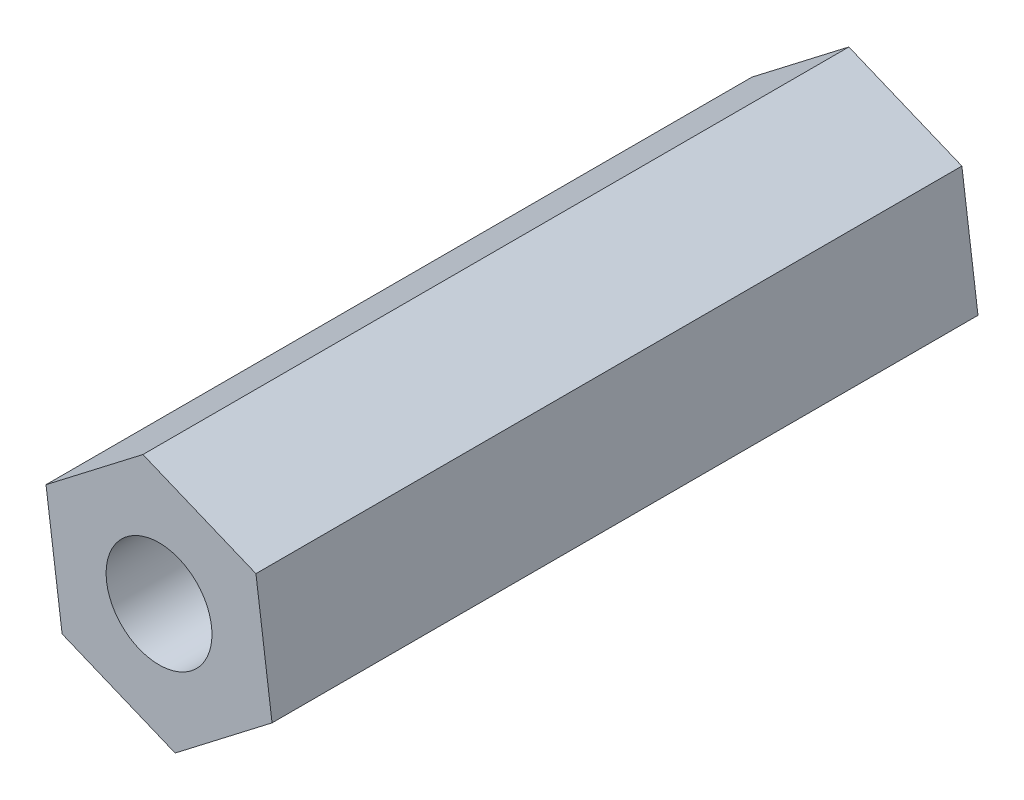
from build123d import *

# Parameters (mm, degrees)
RESSALTO_EXTRUS_O1_DEPTH = 20
ESBO_O2_R                = 1.5
CORTE_EXTRUS_O1_DEPTH    = 20


with BuildPart() as part:
    # Esboço1 → Ressalto-extrusão1 (new body)
    with BuildSketch(Plane.XY):
        Polygon((8.733866008, -0.990987001), (5.531707571, 0.330444551), (2.786235059, -1.781990226), (3.242920984, -5.215856555), (6.445079421, -6.537288107), (9.190551933, -4.424853331), align=None)
    extrude(amount=RESSALTO_EXTRUS_O1_DEPTH)

    # Esboço2 → Corte-extrusão1 (cut)
    with BuildSketch(Plane(origin=(0, 0, 0), x_dir=(-1, 0, 0), z_dir=(0, 0, -1))):
        with Locations((-5.988275058, -3.102531235)):
            Circle(ESBO_O2_R)
    extrude(amount=-CORTE_EXTRUS_O1_DEPTH, mode=Mode.SUBTRACT)


solid = part.part
